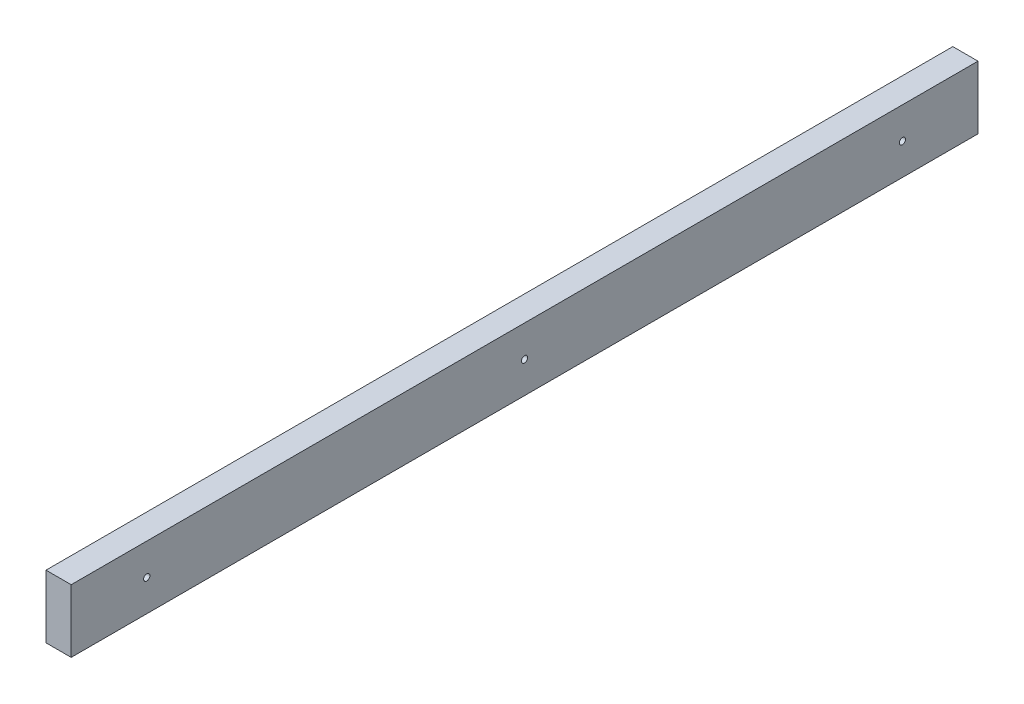
from build123d import *

# Parameters (mm, degrees)
SKETCH1_W          = 12.7
SKETCH1_H          = 31.75
EXTRUDE1_DEPTH     = 228.6
SKETCH2_R          = 1.5875
CUT_EXTRUDE1_DEPTH = 12.7


with BuildPart() as part:
    # Sketch1 → Extrude1 (new body, symmetric)
    with BuildSketch(Plane.XY):
        with Locations((6.35, -15.875)):
            Rectangle(SKETCH1_W, SKETCH1_H)
    extrude(amount=EXTRUDE1_DEPTH, both=True)

    # Sketch2 → Cut-Extrude1 (cut)
    with BuildSketch(Plane(origin=(12.7, 0, 0), x_dir=(0, 0, -1), z_dir=(1, 0, 0))):
        with Locations((-190.5, -15.875)):
            Circle(SKETCH2_R)
        with Locations((190.5, -15.875)):
            Circle(SKETCH2_R)
        with Locations((0, -15.875)):
            Circle(SKETCH2_R)
    extrude(amount=-CUT_EXTRUDE1_DEPTH, mode=Mode.SUBTRACT)


solid = part.part
